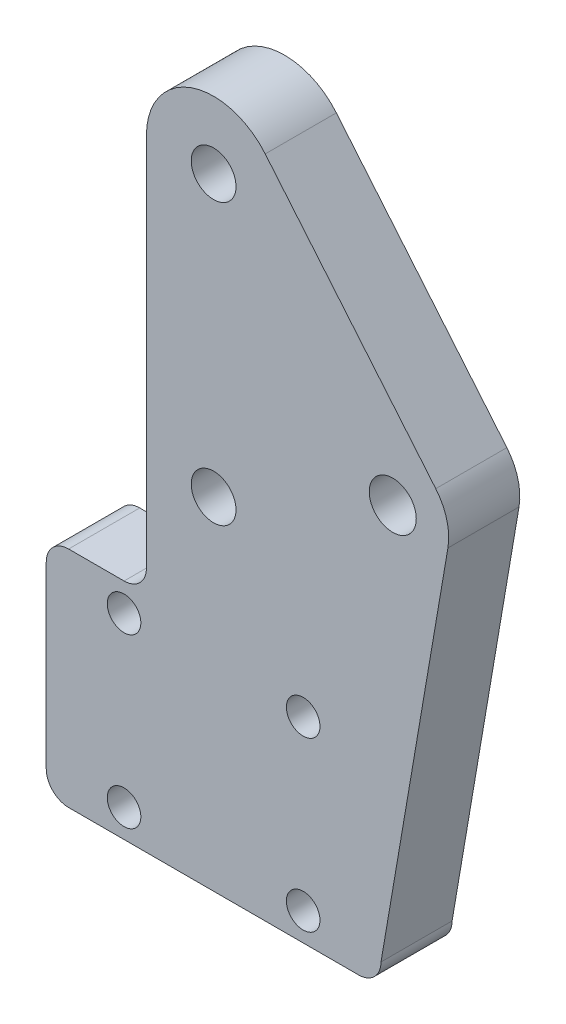
from build123d import *

# Parameters (mm, degrees)
SKETCH1_R           = 1.5
SKETCH1_R_2         = 2
BOSS_EXTRUDE1_DEPTH = 6.35
FILLET1_R           = 2
SKETCH2_R           = 2.1
BOSS_EXTRUDE2_DEPTH = 6.35


with BuildPart() as part:
    # Sketch1 → Boss-Extrude1 (new body)
    with BuildSketch(Plane.XY):
        with BuildLine():
            Line((25.95, 45.499996), (25.95, 9.999996))
            Line((25.95, 9.999996), (34.9, 9.999996))
            Line((34.9, 9.999996), (34.9, -10))
            Line((34.9, -10), (5, -10))
            Line((5, -10), (5, 9.999996))
            Line((5, 9.999996), (13.95, 9.999996))
            Line((13.95, 9.999996), (13.95, 45.499996))
            ThreePointArc((13.95, 45.499996), (19.95, 51.499996), (25.95, 45.499996))
        make_face()
        with Locations((27.95, -7.5)):
            Circle(SKETCH1_R, mode=Mode.SUBTRACT)
        with Locations((11.95, -7.5)):
            Circle(SKETCH1_R, mode=Mode.SUBTRACT)
        with Locations((27.95, 7.5)):
            Circle(SKETCH1_R, mode=Mode.SUBTRACT)
        with Locations((11.95, 7.5)):
            Circle(SKETCH1_R, mode=Mode.SUBTRACT)
        with Locations((19.95, 45.499996)):
            Circle(SKETCH1_R_2, mode=Mode.SUBTRACT)
        with Locations((19.95, 20.499996)):
            Circle(SKETCH1_R_2, mode=Mode.SUBTRACT)
    extrude(amount=BOSS_EXTRUDE1_DEPTH)

    # Fillet1
    fillet1_edges = [part.edges().sort_by_distance(p)[0] for p in [
        (5, 9.999996, 3.175),
        (13.95, 9.999996, 3.175),
        (25.95, 9.999996, 3.175),
        (34.9, 9.999996, 3.175),
        (34.9, -10, 3.175),
        (5, -10, 3.175),
    ]]
    fillet(fillet1_edges, radius=FILLET1_R)

    # Sketch2 → Boss-Extrude2 (add)
    with BuildSketch(Plane.XY.offset(6.35)):
        with BuildLine():
            Line((24.559539107, 49.340848668), (39.791282589, 31.060710557))
            ThreePointArc((39.791282589, 31.060710557), (40.778341906, 29.158889693), (40.87868421, 27.018529882))
            Line((40.87868421, 27.018529882), (34.9, -8))
            Line((34.9, -8), (34.9, 7.999996))
            ThreePointArc((34.9, 7.999996), (34.314213562, 9.414209562), (32.9, 9.999996))
            Line((32.9, 9.999996), (27.95, 9.999996))
            ThreePointArc((27.95, 9.999996), (26.535786438, 10.585782437), (25.95, 11.999996))
            Line((25.95, 11.999996), (25.95, 45.499996))
            ThreePointArc((25.95, 45.499996), (25.591685681, 47.542392308), (24.559539107, 49.340848668))
        make_face()
        with Locations((35.95, 27.86)):
            Circle(SKETCH2_R, mode=Mode.SUBTRACT)
    extrude(amount=-BOSS_EXTRUDE2_DEPTH)


solid = part.part
